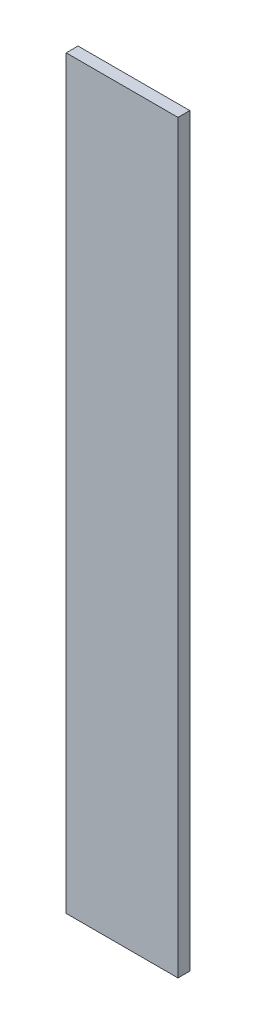
from build123d import *

# Parameters (mm, degrees)
SKETCH1_W           = 30
SKETCH1_H           = 200
BOSS_EXTRUDE1_DEPTH = 3.175


with BuildPart() as part:
    # Sketch1 → Boss-Extrude1 (new body)
    with BuildSketch(Plane.XY):
        Rectangle(SKETCH1_W, SKETCH1_H)
    extrude(amount=BOSS_EXTRUDE1_DEPTH)


solid = part.part
